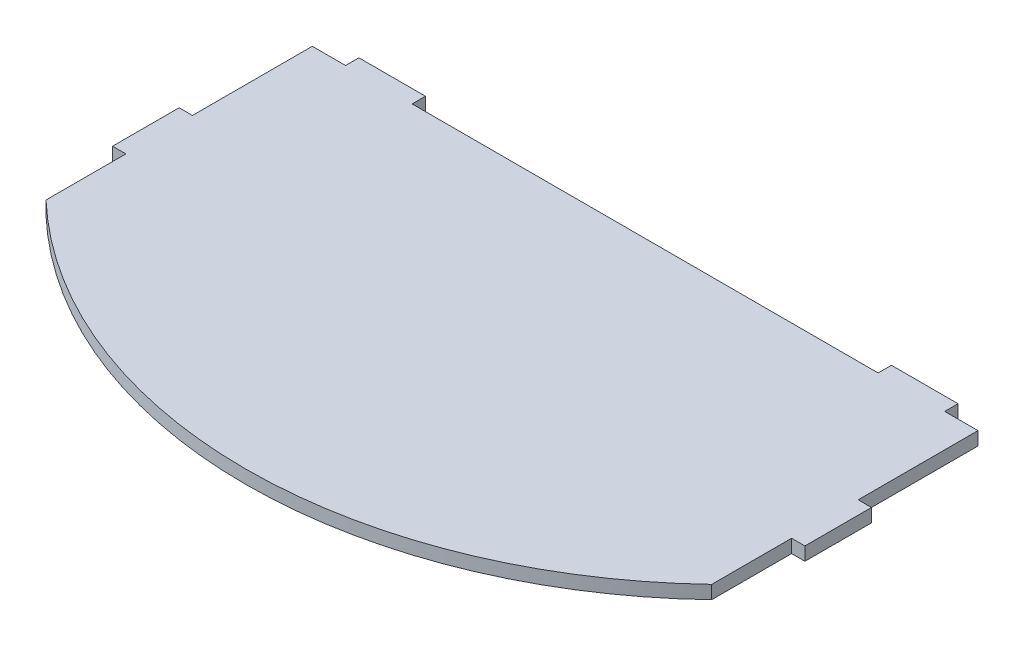
from build123d import *

# Parameters (mm, degrees)
EXTRUDE1_DEPTH = 4


with BuildPart() as part:
    # Sketch1 → Extrude1 (new body)
    with BuildSketch(Plane(origin=(0, 0, 0), x_dir=(1, 0, 0), z_dir=(0, 1, 0))):
        with BuildLine():
            Line((-90, 60), (-100, 60))
            Line((-100, 60), (-100, 24))
            Line((-100, 24), (-104, 24))
            Line((-104, 24), (-104, 4))
            Line((-104, 4), (-100, 4))
            Line((-100, 4), (-100, -20))
            ThreePointArc((-100, -20), (0, -60), (100, -20))
            Line((100, -20), (100, 4))
            Line((100, 4), (104, 4))
            Line((104, 4), (104, 24))
            Line((104, 24), (100, 24))
            Line((100, 24), (100, 60))
            Line((100, 60), (90, 60))
            Line((90, 60), (90, 64))
            Line((90, 64), (70, 64))
            Line((70, 64), (70, 60))
            Line((70, 60), (-70, 60))
            Line((-70, 60), (-70, 64))
            Line((-70, 64), (-90, 64))
            Line((-90, 64), (-90, 60))
        make_face()
    extrude(amount=EXTRUDE1_DEPTH)


solid = part.part
